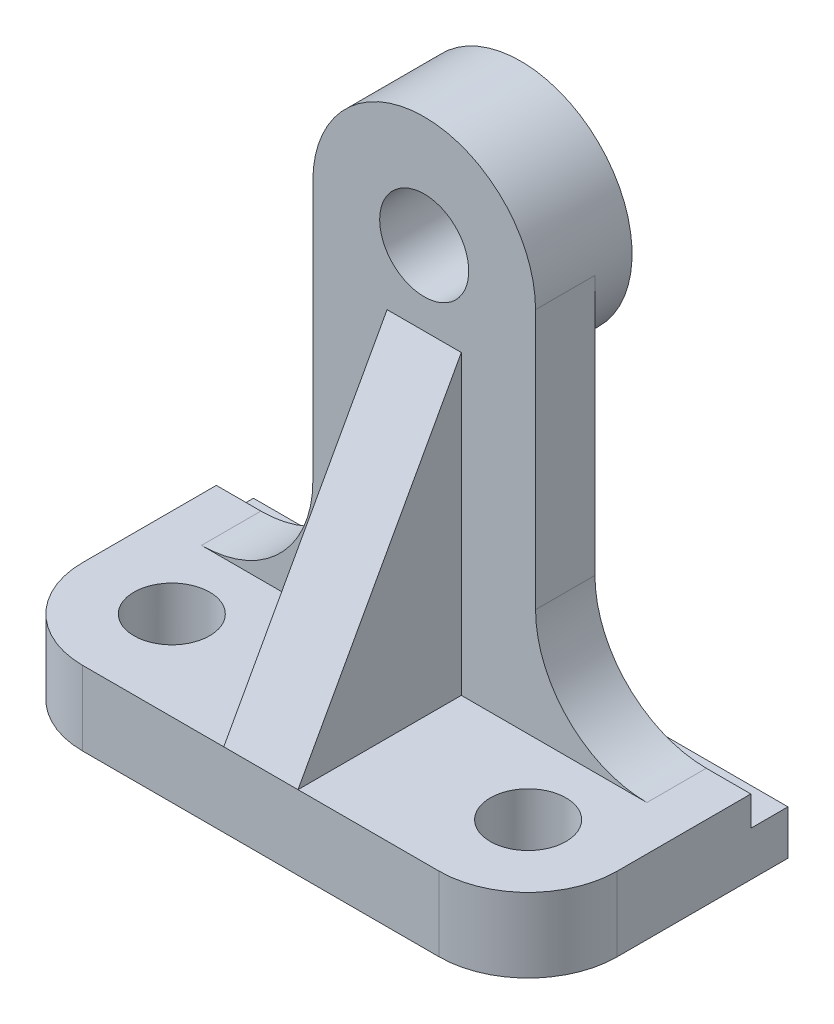
from build123d import *

# Parameters (mm, degrees)
SKETCH1_W           = 72
SKETCH1_H           = 35
BOSS_EXTRUDE1_DEPTH = 10
FILLET1_R           = 12
SKETCH3_W           = 5
SKETCH3_H           = 4
CUT_EXTRUDE1_DEPTH  = 75.767974428
SKETCH4_R           = 6
BOSS_EXTRUDE2_DEPTH = 8
FILLET2_R           = 15
M12_TAPPED_HOLE1_D  = 10.2
SKETCH7_R           = 15
SKETCH7_R_2         = 6
BOSS_EXTRUDE3_DEPTH = 5
RIB1_REACH          = 87.013
SKETCH8_WALL_W      = 217.67731737
SKETCH8_WALL_H      = 10


with BuildPart() as part:
    # Sketch1 → Boss-Extrude1 (new body)
    with BuildSketch(Plane(origin=(0, 0, 0), x_dir=(1, 0, 0), z_dir=(0, 1, 0))):
        Rectangle(SKETCH1_W, SKETCH1_H)
    extrude(amount=BOSS_EXTRUDE1_DEPTH)

    # Fillet1
    fillet1_edges = [part.edges().sort_by_distance(p)[0] for p in [
        (36, 5, 17.5),
        (-36, 5, 17.5),
    ]]
    fillet(fillet1_edges, radius=FILLET1_R)

    # Sketch3 → Cut-Extrude1 (cut, through all)
    with BuildSketch(Plane(origin=(36, 0, 0), x_dir=(0, 0, -1), z_dir=(1, 0, 0))):
        with Locations((15, 8)):
            Rectangle(SKETCH3_W, SKETCH3_H)
    extrude(amount=-CUT_EXTRUDE1_DEPTH, mode=Mode.SUBTRACT)

    # Sketch4 → Boss-Extrude2 (add)
    with BuildSketch(Plane(origin=(0, 0, -12.5), x_dir=(-1, 0, 0), z_dir=(0, 0, -1))):
        with BuildLine():
            Line((-15, 10), (15, 10))
            Line((15, 10), (15, 60))
            ThreePointArc((15, 60), (0, 75), (-15, 60))
            Line((-15, 60), (-15, 10))
        make_face()
        with Locations((0, 60)):
            Circle(SKETCH4_R, mode=Mode.SUBTRACT)
    extrude(amount=-BOSS_EXTRUDE2_DEPTH)

    # Fillet2
    fillet2_edges = [part.edges().sort_by_distance(p)[0] for p in [
        (15, 10, -8.5),
        (-15, 10, -8.5),
    ]]
    fillet(fillet2_edges, radius=FILLET2_R)

    # M12 Tapped Hole1 (through all)
    with Locations(Plane(origin=(0, 10, 0), x_dir=(1, 0, 0), z_dir=(0, 1, 0))):
        with Locations((-24, -5.5), (24, -5.5)):
            Hole(M12_TAPPED_HOLE1_D / 2)

    # Sketch7 → Boss-Extrude3 (add)
    with BuildSketch(Plane(origin=(0, 0, -12.5), x_dir=(-1, 0, 0), z_dir=(0, 0, -1))):
        with Locations((0, 60)):
            Circle(SKETCH7_R)
        with Locations((0, 60)):
            Circle(SKETCH7_R_2, mode=Mode.SUBTRACT)
    extrude(amount=BOSS_EXTRUDE3_DEPTH)

    # Sketch8 wall → Rib1 (add, up to next)
    with BuildSketch(Plane(origin=(0, 30, 6.5), x_dir=(0, -0.876215908677, 0.481918749772), z_dir=(0, -0.481918749772, -0.876215908677)), mode=Mode.PRIVATE) as rib1_sk1:
        Rectangle(SKETCH8_WALL_W, SKETCH8_WALL_H)
    rib1_tool1 = extrude(rib1_sk1.sketch, amount=RIB1_REACH, mode=Mode.PRIVATE) - part.part
    add(rib1_tool1.solids().sort_by_distance((0, 30, 6.5))[0])


solid = part.part
